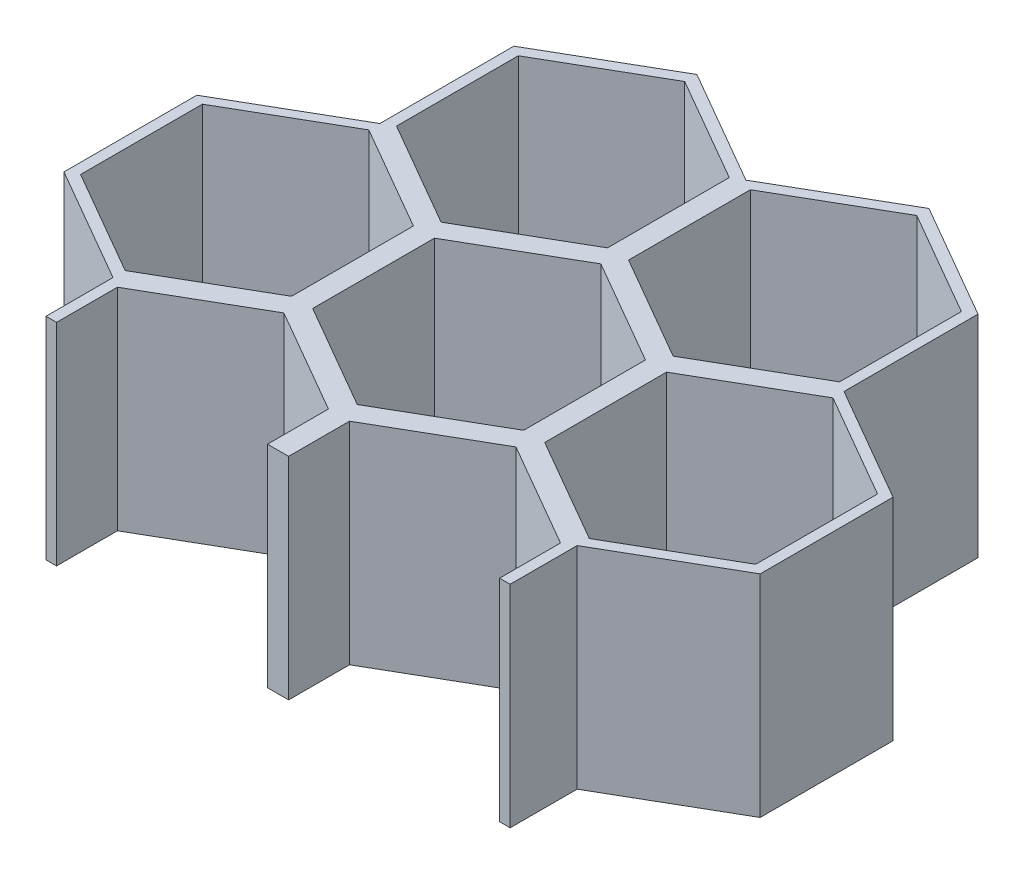
from build123d import *

# Parameters (mm, degrees)
BOSS_EXTRUDE2_DEPTH = 20
CUT_EXTRUDE1_DEPTH  = 21
CUT_EXTRUDE2_DEPTH  = 21


with BuildPart() as part:
    # Sketch1 → Boss-Extrude2 (new body)
    with BuildSketch(Plane(origin=(0, 0, 0), x_dir=(1, 0, 0), z_dir=(0, 1, 0))):
        Polygon((21, -13.279056191), (21, -19.052558883), (23, -19.052558883), (23, -13.279056191), (33, -7.505553499), (43, -13.279056191), (43, -19.052558883), (45, -19.052558883), (45, -13.279056191), (55, -7.505553499), (65, -13.279056191), (65, -19.052558883), (67, -19.052558883), (67, -13.279056191), (77, -7.505553499), (77, 7.400435733), (67, 13.173938425), (67, 24.720943809), (77, 30.494446501), (77, 38), (76, 38), (76, 32.226497308), (66, 26.452994616), (56, 32.226497308), (56, 38), (54, 38), (54, 32.226497308), (44, 26.452994616), (34, 32.226497308), (34, 38), (32, 38), (32, 32.226497308), (22, 26.452994616), (12, 32.226497308), (12, 38), (11, 38), (11, 30.494446501), (21, 24.720943809), (21, 13.173938425), (11, 7.400435733), (11, -7.505553499), align=None)
        Polygon((12, 5.773502692), (22, 11.547005384), (32, 5.773502692), (32, -5.773502692), (22, -11.547005384), (12, -5.773502692), align=None, mode=Mode.SUBTRACT)
        Polygon((34, 5.773502692), (44, 11.547005384), (54, 5.773502692), (54, -5.773502692), (44, -11.547005384), (34, -5.773502692), align=None, mode=Mode.SUBTRACT)
        Polygon((56, 5.773502692), (66, 11.547005384), (76, 5.773502692), (76, -5.773502692), (66, -11.547005384), (56, -5.773502692), align=None, mode=Mode.SUBTRACT)
        Polygon((43, 13.173938425), (33, 7.400435733), (23, 13.173938425), (23, 24.720943809), (33, 30.494446501), (43, 24.720943809), align=None, mode=Mode.SUBTRACT)
        Polygon((65, 13.173938425), (55, 7.400435733), (45, 13.173938425), (45, 24.720943809), (55, 30.494446501), (65, 24.720943809), align=None, mode=Mode.SUBTRACT)
    extrude(amount=BOSS_EXTRUDE2_DEPTH)

    # Sketch2 → Cut-Extrude1 (cut, through all)
    with BuildSketch(Plane(origin=(0, 20, 0), x_dir=(1, 0, 0), z_dir=(0, 1, 0))):
        Polygon((11, 6.245735195), (22, 12.596588156), (22, 25.298294078), (11, 31.649147039), (2.295872016, -19.052558883), (22, -19.052558883), (22, -12.701705922), (11, -6.350852961), align=None)
        Polygon((77, 31.649147039), (85.704127984, -19.052558883), (66, -19.052558883), (66, -12.701705922), (77, -6.350852961), (77, 6.245735195), (66, 12.596588156), (66, 25.298294078), align=None)
    extrude(amount=-CUT_EXTRUDE1_DEPTH, mode=Mode.SUBTRACT)

    # Sketch4 → Cut-Extrude2 (cut, through all)
    with BuildSketch(Plane(origin=(0, 20, 0), x_dir=(1, 0, 0), z_dir=(0, 1, 0))):
        Polygon((22, 25.298294078), (33, 31.649147039), (44, 25.298294078), (55, 31.649147039), (66, 25.298294078), (77, 31.649147039), (77, 38), (11, 38), (11, 31.649147039), align=None)
    extrude(amount=-CUT_EXTRUDE2_DEPTH, mode=Mode.SUBTRACT)


solid = part.part
